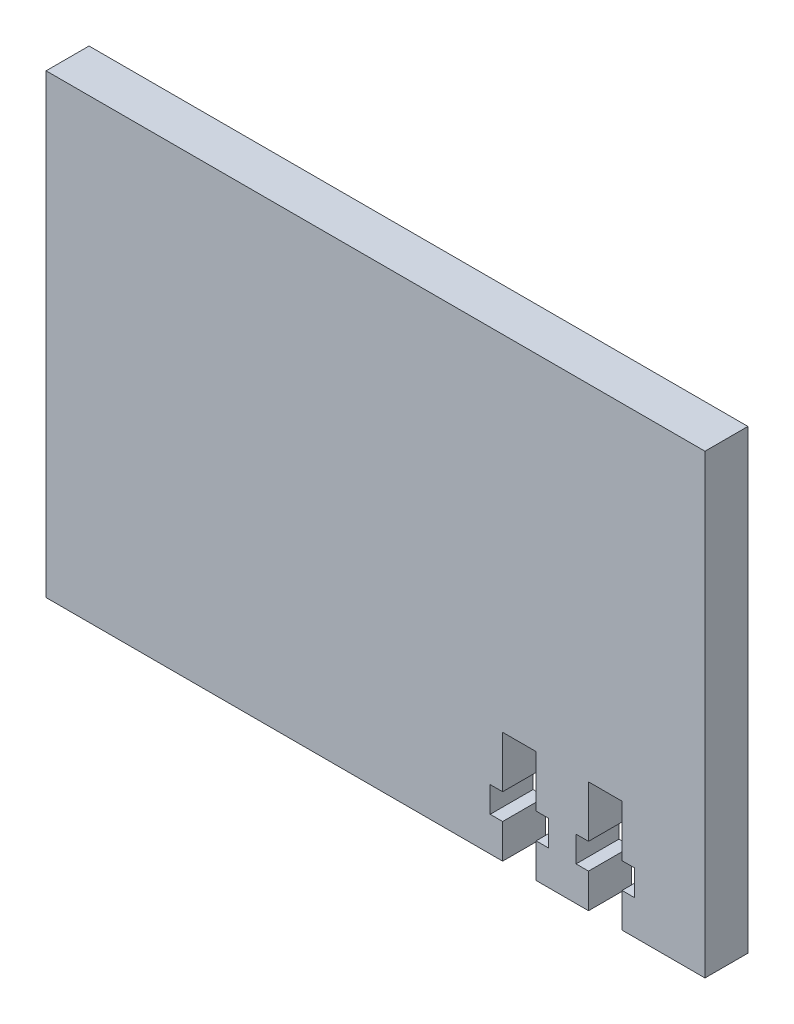
from build123d import *

# Parameters (mm, degrees)
SKETCH2_W           = 76.718161642
SKETCH2_H           = 53.12
BOSS_EXTRUDE1_DEPTH = 5
CUT_EXTRUDE1_DEPTH  = 10


with BuildPart() as part:
    # Sketch2 → Boss-Extrude1 (new body)
    with BuildSketch(Plane(origin=(0, 0, 0), x_dir=(-1, 0, 0), z_dir=(0, 0, -1))):
        with Locations((184.636580821, -28.44)):
            Rectangle(SKETCH2_W, SKETCH2_H)
    extrude(amount=BOSS_EXTRUDE1_DEPTH)

    # Sketch3 → Cut-Extrude1 (cut)
    with BuildSketch(Plane(origin=(0, 0, -5), x_dir=(-1, 0, 0), z_dir=(0, 0, -1))):
        Polygon((155.9375, -55), (155.9375, -51), (154.4875, -51), (154.4875, -48), (155.9375, -48), (155.9375, -42), (159.8375, -42), (159.8375, -48), (161.2875, -48), (161.2875, -51), (159.8375, -51), (159.8375, -55), align=None)
        Polygon((165.9375, -55), (165.9375, -51), (164.4875, -51), (164.4875, -48), (165.9375, -48), (165.9375, -42), (169.8375, -42), (169.8375, -48), (171.2875, -48), (171.2875, -51), (169.8375, -51), (169.8375, -55), align=None)
    extrude(amount=-CUT_EXTRUDE1_DEPTH, mode=Mode.SUBTRACT)


solid = part.part
